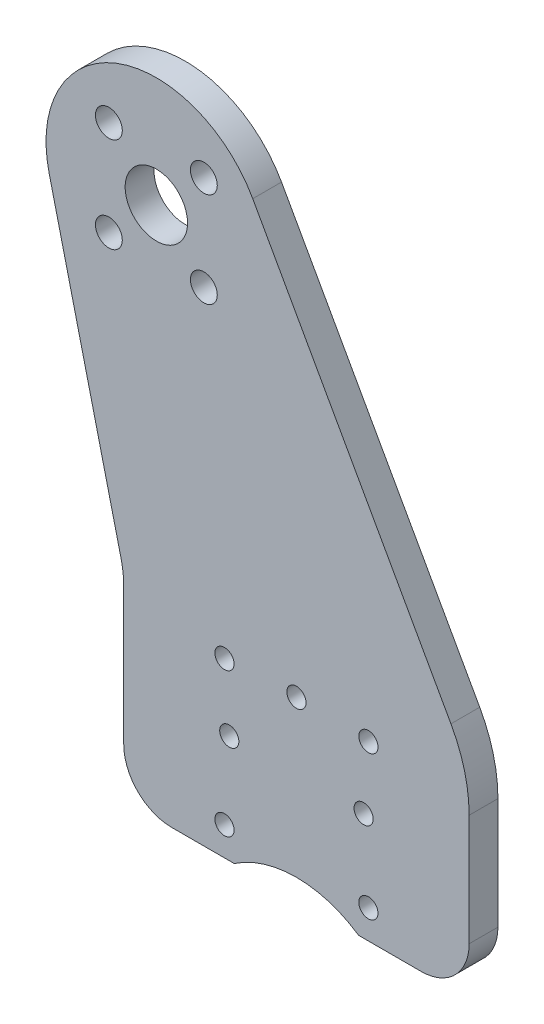
from build123d import *

# Parameters (mm, degrees)
SKETCH_1_R      = 3.25
SKETCH_1_R_2    = 1.4
SKETCH_1_R_3    = 1
EXTRUDE_1_DEPTH = 3


with BuildPart() as part:
    # Эскиз1 → Бобышка-Вытянуть1 (new body)
    with BuildSketch(Plane.XY):
        with BuildLine():
            Line((1.6, -55.377499952), (8.119259302, -55.377499952))
            ThreePointArc((8.119259302, -55.377499952), (14.6, -53.377499952), (21.080740698, -55.377499952))
            Line((21.080740698, -55.377499952), (27.6, -55.377499952))
            ThreePointArc((27.6, -55.377499952), (31.135533906, -53.913033858), (32.6, -50.377499952))
            Line((32.6, -50.377499952), (32.6, -38.774674064))
            ThreePointArc((32.6, -38.774674064), (32.11800347, -35.002728245), (30.702989966, -31.473191066))
            Line((30.702989966, -31.473191066), (10.04562564, 5.597803631))
            ThreePointArc((10.04562564, 5.597803631), (-4.188430146, 10.710137857), (-11.17802813, -2.702163414))
            Line((-11.17802813, -2.702163414), (-3.679975539, -33.719326307))
            ThreePointArc((-3.679975539, -33.719326307), (-3.470240572, -34.885869352), (-3.4, -36.069033624))
            Line((-3.4, -36.069033624), (-3.4, -50.377499952))
            ThreePointArc((-3.4, -50.377499952), (-1.935533906, -53.913033858), (1.6, -55.377499952))
        make_face()
        Circle(SKETCH_1_R, mode=Mode.SUBTRACT)
        with Locations((-4.949747468, 4.949747468)):
            Circle(SKETCH_1_R_2, mode=Mode.SUBTRACT)
        with Locations((4.949747468, 4.949747468)):
            Circle(SKETCH_1_R_2, mode=Mode.SUBTRACT)
        with Locations((4.949747468, -4.949747468)):
            Circle(SKETCH_1_R_2, mode=Mode.SUBTRACT)
        with Locations((-4.949747468, -4.949747468)):
            Circle(SKETCH_1_R_2, mode=Mode.SUBTRACT)
        with Locations((7.1, -37.377499952)):
            Circle(SKETCH_1_R_3, mode=Mode.SUBTRACT)
        with Locations((22.1, -37.377499952)):
            Circle(SKETCH_1_R_3, mode=Mode.SUBTRACT)
        with Locations((7.1, -52.377499952)):
            Circle(SKETCH_1_R_3, mode=Mode.SUBTRACT)
        with Locations((22.1, -52.377499952)):
            Circle(SKETCH_1_R_3, mode=Mode.SUBTRACT)
        with Locations((14.6, -37.127499952)):
            Circle(SKETCH_1_R_3, mode=Mode.SUBTRACT)
        with Locations((21.6, -44.127499952)):
            Circle(SKETCH_1_R_3, mode=Mode.SUBTRACT)
        with Locations((7.6, -44.127499952)):
            Circle(SKETCH_1_R_3, mode=Mode.SUBTRACT)
    extrude(amount=-EXTRUDE_1_DEPTH)


solid = part.part
